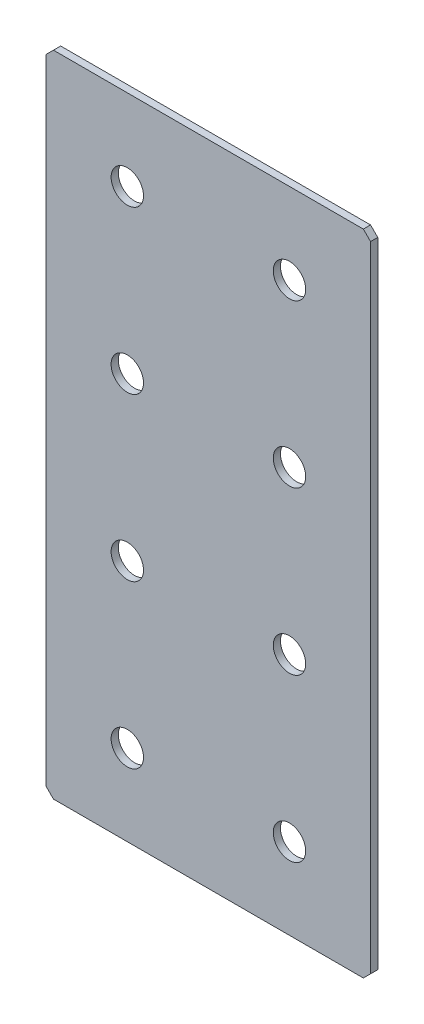
from build123d import *

# Parameters (mm, degrees)
SKETCH_1_W        = 90
SKETCH_1_H        = 180
EXTRUDE_1_DEPTH   = 2
CHAMFER_1_SIZE    = 2
HOLE_WIZARD_M81_D = 9


with BuildPart() as part:
    # Эскиз1 → Бобышка-Вытянуть1 (new body)
    with BuildSketch(Plane.XY):
        Rectangle(SKETCH_1_W, SKETCH_1_H)
    extrude(amount=EXTRUDE_1_DEPTH)

    # Фаска1
    chamfer_1_edges = [part.edges().sort_by_distance(p)[0] for p in [
        (45, -90, 1),
        (-45, -90, 1),
        (-45, 90, 1),
        (45, 90, 1),
    ]]
    chamfer(chamfer_1_edges, length=CHAMFER_1_SIZE)

    # Отверстие с зазором M81 (through all)
    with Locations(Plane.XY.offset(2)):
        with Locations((-22.5, 22.5), (22.5, 22.5), (-22.5, -22.5), (22.5, -22.5), (-22.5, 67.5), (22.5, 67.5), (22.5, -67.5), (-22.5, -67.5)):
            Hole(HOLE_WIZARD_M81_D / 2)


solid = part.part
